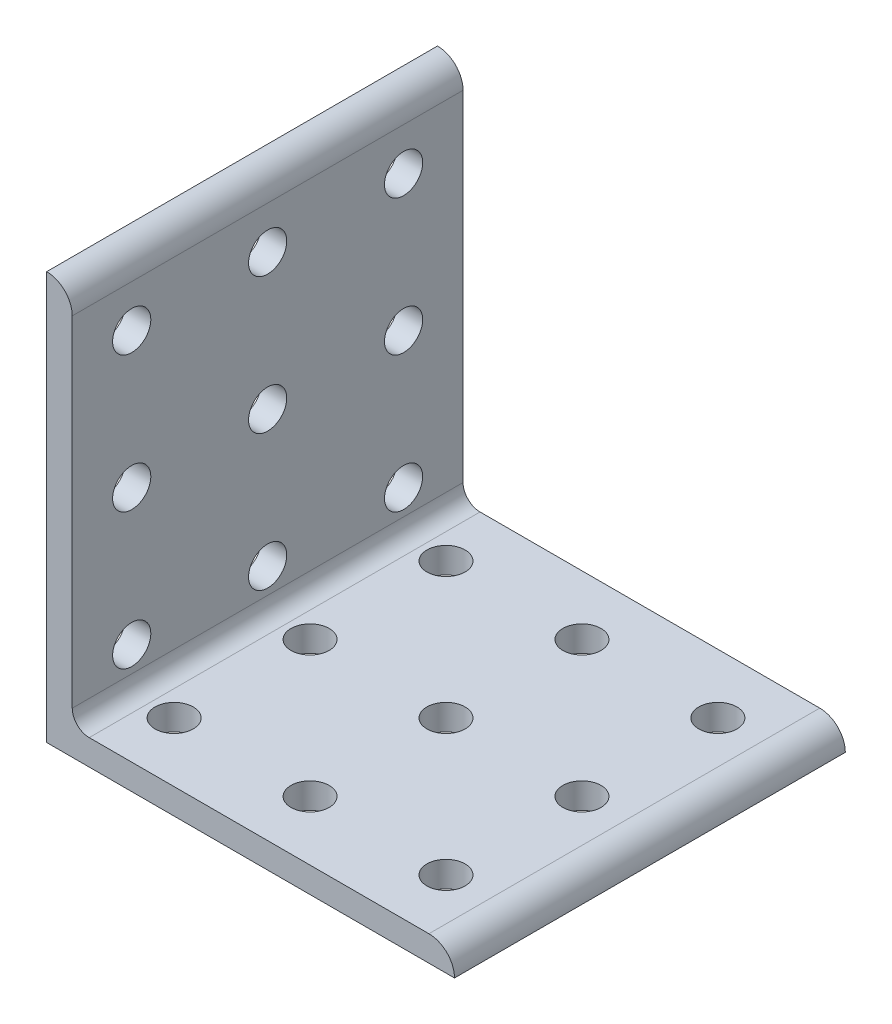
from build123d import *

# Parameters (mm, degrees)
BOSS_EXTRUDE1_DEPTH      = 36.5125
BOSS_EXTRUDE1_DEPTH_BACK = 36.5125
SKETCH4_R                = 3.5687
CUT_EXTRUDE1_DEPTH       = 5.7752
SKETCH5_R                = 3.5687
CUT_EXTRUDE2_DEPTH       = 5.7752


with BuildPart() as part:
    # Sketch3 → Boss-Extrude1 (new body, two sides)
    with BuildSketch(Plane.XY) as boss_extrude1_sk:
        with BuildLine():
            Line((-38.1, 38.1), (-38.1, -38.1))
            Line((-38.1, -38.1), (38.1, -38.1))
            ThreePointArc((38.1, -38.1), (36.701376302, -34.723423698), (33.3248, -33.3248))
            Line((33.3248, -33.3248), (-30.1498, -33.3248))
            ThreePointArc((-30.1498, -33.3248), (-32.39486403, -32.39486403), (-33.3248, -30.1498))
            Line((-33.3248, -30.1498), (-33.3248, 33.3248))
            ThreePointArc((-33.3248, 33.3248), (-34.723423698, 36.701376302), (-38.1, 38.1))
        make_face()
    extrude(amount=BOSS_EXTRUDE1_DEPTH)
    extrude(boss_extrude1_sk.sketch, amount=-BOSS_EXTRUDE1_DEPTH_BACK)

    # Sketch4 → Cut-Extrude1 (cut, through all)
    with BuildSketch(Plane(origin=(-33.3248, 0, 0), x_dir=(0, 0, -1), z_dir=(1, 0, 0))):
        with Locations((-25.4, -25.4)):
            Circle(SKETCH4_R)
        with Locations((0, -25.4)):
            Circle(SKETCH4_R)
        with Locations((25.4, -25.4)):
            Circle(SKETCH4_R)
        Circle(SKETCH4_R)
        with Locations((25.4, 0)):
            Circle(SKETCH4_R)
        with Locations((0, 25.4)):
            Circle(SKETCH4_R)
        with Locations((25.4, 25.4)):
            Circle(SKETCH4_R)
        with Locations((-25.4, 0)):
            Circle(SKETCH4_R)
        with Locations((-25.4, 25.4)):
            Circle(SKETCH4_R)
    extrude(amount=-CUT_EXTRUDE1_DEPTH, mode=Mode.SUBTRACT)

    # Sketch5 → Cut-Extrude2 (cut, through all)
    with BuildSketch(Plane(origin=(0, -33.3248, -33.3248), x_dir=(1, 0, 0), z_dir=(0, 1, 0))):
        with Locations((-25.4, -58.7248)):
            Circle(SKETCH5_R)
        with Locations((0, -58.7248)):
            Circle(SKETCH5_R)
        with Locations((25.4, -58.7248)):
            Circle(SKETCH5_R)
        with Locations((0, -33.3248)):
            Circle(SKETCH5_R)
        with Locations((25.4, -33.3248)):
            Circle(SKETCH5_R)
        with Locations((0, -7.9248)):
            Circle(SKETCH5_R)
        with Locations((25.4, -7.9248)):
            Circle(SKETCH5_R)
        with Locations((-25.4, -33.3248)):
            Circle(SKETCH5_R)
        with Locations((-25.4, -7.9248)):
            Circle(SKETCH5_R)
    extrude(amount=-CUT_EXTRUDE2_DEPTH, mode=Mode.SUBTRACT)


solid = part.part
